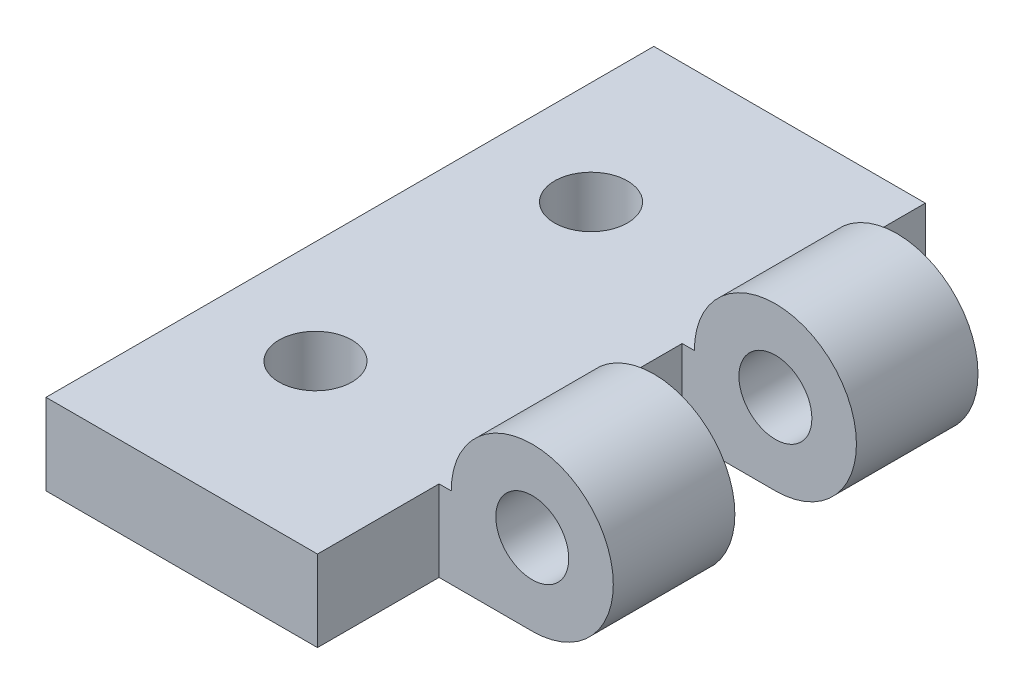
from build123d import *

# Parameters (mm, degrees)
BOSS_EXTRUDE1_DEPTH     = 38.1
SKETCH3_R               = 2.286
CUT_EXTRUDE2_DEPTH      = 6.08
SKETCH4_W               = 10.922
SKETCH4_H               = 7.62
CUT_EXTRUDE3_DEPTH      = 6.08
CUT_EXTRUDE3_DEPTH_BACK = 6.08
SKETCH7_R               = 2.286
CUT_EXTRUDE4_DEPTH      = 31.48


with BuildPart() as part:
    # Sketch1 → Boss-Extrude1 (new body)
    with BuildSketch(Plane.XY):
        with BuildLine():
            Line((0, 0), (0, 5.08))
            Line((0, 5.08), (17.78, 5.08))
            ThreePointArc((17.78, 5.08), (26.452102448, 8.672102448), (22.86, 0))
            Line((22.86, 0), (0, 0))
        make_face()
    extrude(amount=BOSS_EXTRUDE1_DEPTH)

    # Sketch3 → Cut-Extrude2 (cut, through all)
    with BuildSketch(Plane(origin=(0, 5.08, 0), x_dir=(1, 0, 0), z_dir=(0, 1, 0))):
        with Locations((6.477, -10.414)):
            Circle(SKETCH3_R)
        with Locations((6.477, -27.686)):
            Circle(SKETCH3_R)
    extrude(amount=-CUT_EXTRUDE2_DEPTH, mode=Mode.SUBTRACT)

    # Sketch4 → Cut-Extrude3 (cut, two sides)
    with BuildSketch(Plane(origin=(0, 5.08, 0), x_dir=(1, 0, 0), z_dir=(0, 1, 0))) as cut_extrude3_sk:
        with Locations((22.479, -3.81)):
            Rectangle(SKETCH4_W, SKETCH4_H)
        with Locations((22.479, -34.29)):
            Rectangle(SKETCH4_W, SKETCH4_H)
        with Locations((22.479, -19.05)):
            Rectangle(SKETCH4_W, SKETCH4_H)
    extrude(amount=CUT_EXTRUDE3_DEPTH, mode=Mode.SUBTRACT)
    extrude(cut_extrude3_sk.sketch, amount=-CUT_EXTRUDE3_DEPTH_BACK, mode=Mode.SUBTRACT)

    # Sketch7 → Cut-Extrude4 (cut, through all)
    with BuildSketch(Plane.XY.offset(30.48)):
        with Locations((22.86, 5.08)):
            Circle(SKETCH7_R)
    extrude(amount=-CUT_EXTRUDE4_DEPTH, mode=Mode.SUBTRACT)


solid = part.part
